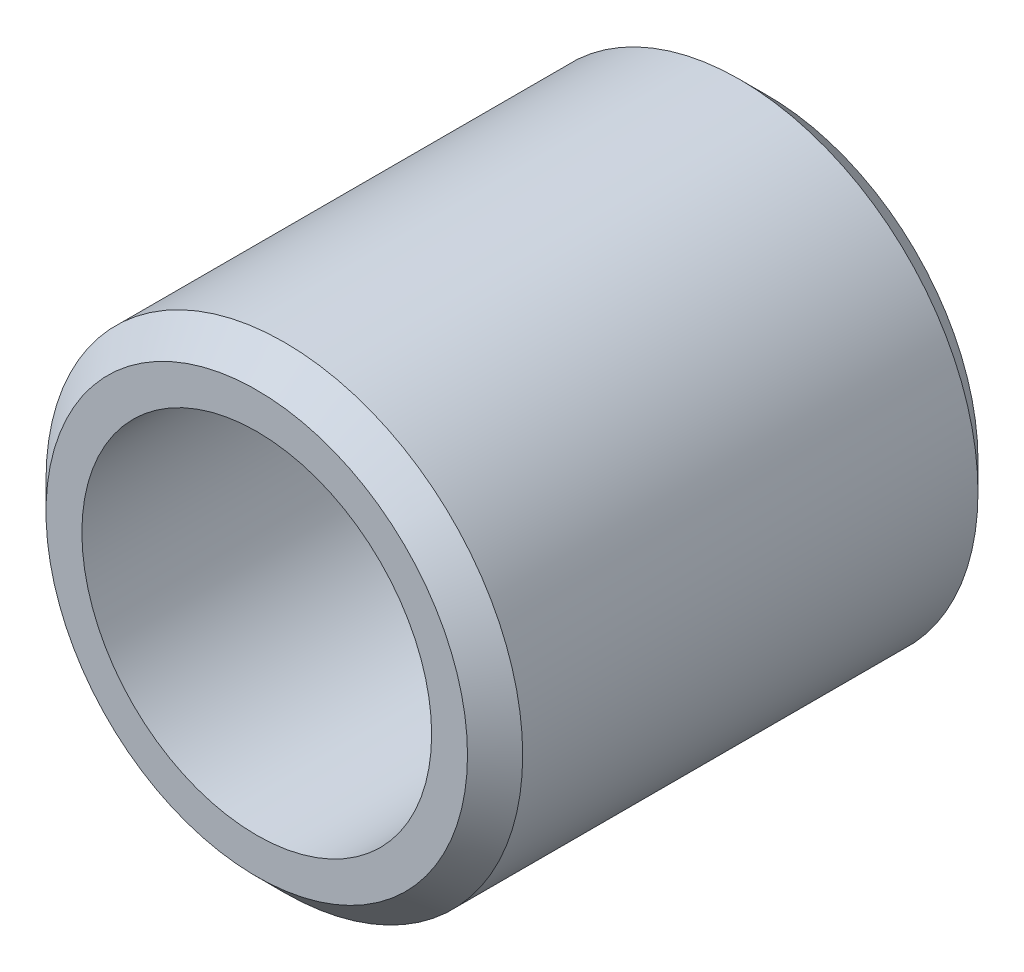
from build123d import *


with BuildPart() as part:
    # Sketch1 → Revolve1 (revolve)
    with BuildSketch(Plane(origin=(0, 0, 0), x_dir=(0, 0, -1), z_dir=(1, 0, 0))):
        Polygon((-4.699, 3.87985), (-4.699, 3.21945), (4.699, 3.21945), (4.699, 3.87985), (4.191, 4.38785), (-4.191, 4.38785), align=None)
    revolve(axis=Axis((0, 0, -4.699), (0, 0, 1)))


solid = part.part
